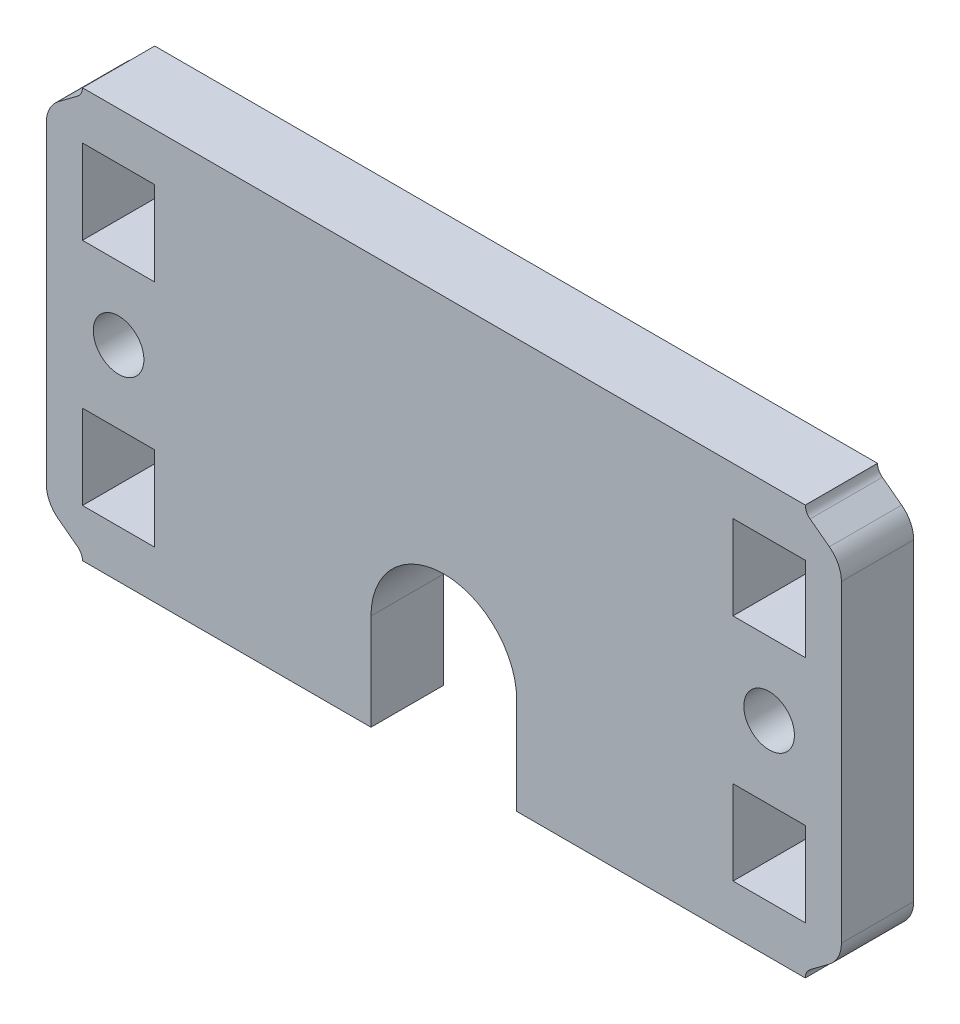
from build123d import *

# Parameters (mm, degrees)
SKETCH_1_W           = 60
SKETCH_1_H           = 34
EXTRUDE_1_DEPTH      = 6
CUT_EXTRUDE_1_DEPTH  = 7
EXTRUDE_2_DEPTH      = 6
SKETCH_3_R           = 2.1
SKETCH_3_W           = 7
SKETCH_3_H           = 6
CUT_EXTRUDE_11_DEPTH = 7
EXTRUDE_21_DEPTH     = 6
SKETCH_31_R          = 2.1
SKETCH_31_W          = 7
SKETCH_31_H          = 6
CUT_EXTRUDE_12_DEPTH = 7


with BuildPart() as part:
    # Эскиз1 → Бобышка-Вытянуть1 (new body)
    with BuildSketch(Plane.XY):
        with Locations((4.02043073, 14.078379342)):
            Rectangle(SKETCH_1_W, SKETCH_1_H)
    extrude(amount=EXTRUDE_1_DEPTH)

    # Эскиз2 → Вырез-Вытянуть1 (cut, through all)
    with BuildSketch(Plane.XY.offset(6)):
        with BuildLine():
            Line((-2.02956927, -2.921620658), (-2.02956927, 5.078379342))
            ThreePointArc((-2.02956927, 5.078379342), (4.02043073, 11.128379342), (10.07043073, 5.078379342))
            Line((10.07043073, 5.078379342), (10.07043073, -2.921620658))
            ThreePointArc((10.07043073, -2.921620658), (4.02043073, -8.971620658), (-2.02956927, -2.921620658))
        make_face()
    extrude(amount=-CUT_EXTRUDE_1_DEPTH, mode=Mode.SUBTRACT)

    # Эскиз21 → Бобышка-Вытянуть2 (add)
    with BuildSketch(Plane(origin=(24.02043073, 14.078379342, 6), x_dir=(0, -1, 0), z_dir=(0, 0, -1))):
        with BuildLine():
            Line((13, 53), (-13, 53))
            ThreePointArc((-13, 53), (-14.118033989, 52.736067977), (-15, 52))
            Line((-15, 52), (-16.2, 50.4))
            ThreePointArc((-16.2, 50.4), (-16.552786405, 50.105572809), (-17, 50))
            Line((-17, 50), (17, 50))
            ThreePointArc((17, 50), (16.552786405, 50.105572809), (16.2, 50.4))
            Line((16.2, 50.4), (15, 52))
            ThreePointArc((15, 52), (14.118033989, 52.736067977), (13, 53))
        make_face()
    extrude(amount=EXTRUDE_2_DEPTH)

    # Эскиз3 → Вырез-Вытянуть11 (cut, through all)
    with BuildSketch(Plane(origin=(24.02043073, 14.078379342, 0), x_dir=(0, -1, 0), z_dir=(0, 0, -1))):
        with Locations((0, 47)):
            Circle(SKETCH_3_R)
        with Locations((9.531849908, 47)):
            Rectangle(SKETCH_3_W, SKETCH_3_H)
        with Locations((-9.531849908, 47)):
            Rectangle(SKETCH_3_W, SKETCH_3_H)
    extrude(amount=-CUT_EXTRUDE_11_DEPTH, mode=Mode.SUBTRACT)

    # Эскиз22 → Бобышка-Вытянуть21 (add)
    with BuildSketch(Plane(origin=(-15.97956927, 14.078379342, 6), x_dir=(0, 1, 0), z_dir=(0, 0, -1))):
        with BuildLine():
            Line((13, 53), (-13, 53))
            ThreePointArc((-13, 53), (-14.118033989, 52.736067977), (-15, 52))
            Line((-15, 52), (-16.2, 50.4))
            ThreePointArc((-16.2, 50.4), (-16.552786405, 50.105572809), (-17, 50))
            Line((-17, 50), (17, 50))
            ThreePointArc((17, 50), (16.552786405, 50.105572809), (16.2, 50.4))
            Line((16.2, 50.4), (15, 52))
            ThreePointArc((15, 52), (14.118033989, 52.736067977), (13, 53))
        make_face()
    extrude(amount=EXTRUDE_21_DEPTH)

    # Эскиз31 → Вырез-Вытянуть12 (cut, through all)
    with BuildSketch(Plane(origin=(-15.97956927, 14.078379342, 0), x_dir=(0, 1, 0), z_dir=(0, 0, -1))):
        with Locations((0, 47)):
            Circle(SKETCH_31_R)
        with Locations((9.531849908, 47)):
            Rectangle(SKETCH_31_W, SKETCH_31_H)
        with Locations((-9.531849908, 47)):
            Rectangle(SKETCH_31_W, SKETCH_31_H)
    extrude(amount=-CUT_EXTRUDE_12_DEPTH, mode=Mode.SUBTRACT)


solid = part.part
